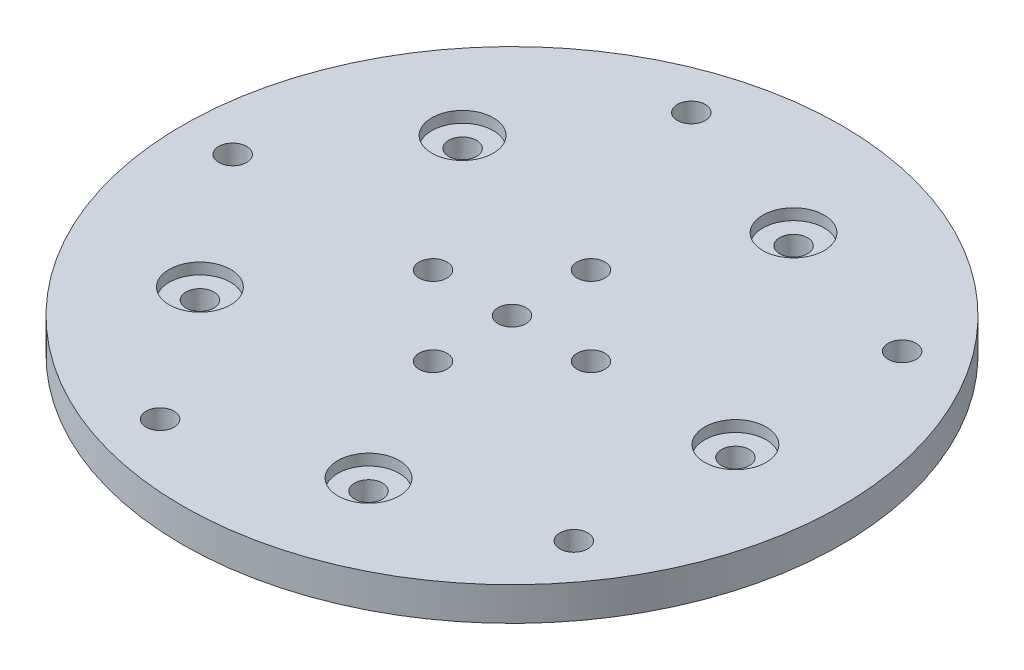
from build123d import *

# Parameters (mm, degrees)
SKETCH_1_R               = 29.5
EXTRUDE_1_DEPTH          = 3
HOLE_WIZARD_M3_4_D       = 2.5
HOLE_WIZARD_M3_1_D       = 2.5
SKETCH_9_R               = 2.75
CUT_EXTRUDE_1_DEPTH      = 1
CUT_EXTRUDE_1_DEPTH_BACK = 1


with BuildPart() as part:
    # 草图1 → 凸台-拉伸1 (new body)
    with BuildSketch(Plane(origin=(0, 0, 0), x_dir=(1, 0, 0), z_dir=(0, 1, 0))):
        Circle(SKETCH_1_R)
    extrude(amount=EXTRUDE_1_DEPTH)

    # M3 螺纹孔4 (through all)
    with Locations(Plane(origin=(0, 3, 0), x_dir=(1, 0, 0), z_dir=(0, 1, 0))):
        with Locations((6.180339887, 19.021130326), (20, 0), (6.180339887, -19.021130326), (-16.180339887, -11.755705046), (-16.180339887, 11.755705046)):
            Hole(HOLE_WIZARD_M3_4_D / 2)

    # M3 螺纹孔1 (through all)
    with Locations(Plane(origin=(0, 3, 0), x_dir=(1, 0, 0), z_dir=(0, 1, 0))):
        with Locations((20.225424859, -14.694631307), (-25, 0), (-7.071067812, 0), (-7.725424859, 23.776412907), (20.225424859, 14.694631307), (-7.725424859, -23.776412907), (0, 0), (0, 7.071067812), (7.071067812, 0), (0, -7.071067812)):
            Hole(HOLE_WIZARD_M3_1_D / 2)

    # 草图9 → 切除-拉伸1 (cut, two sides)
    with BuildSketch(Plane(origin=(0, 3, 0), x_dir=(1, 0, 0), z_dir=(0, 1, 0))) as cut_extrude_1_sk:
        with Locations((20, 0)):
            Circle(SKETCH_9_R)
        with Locations((6.180339887, -19.021130326)):
            Circle(SKETCH_9_R)
        with Locations((-16.180339887, -11.755705046)):
            Circle(SKETCH_9_R)
        with Locations((-16.180339887, 11.755705046)):
            Circle(SKETCH_9_R)
        with Locations((6.180339887, 19.021130326)):
            Circle(SKETCH_9_R)
    extrude(amount=CUT_EXTRUDE_1_DEPTH, mode=Mode.SUBTRACT)
    extrude(cut_extrude_1_sk.sketch, amount=-CUT_EXTRUDE_1_DEPTH_BACK, mode=Mode.SUBTRACT)


solid = part.part
